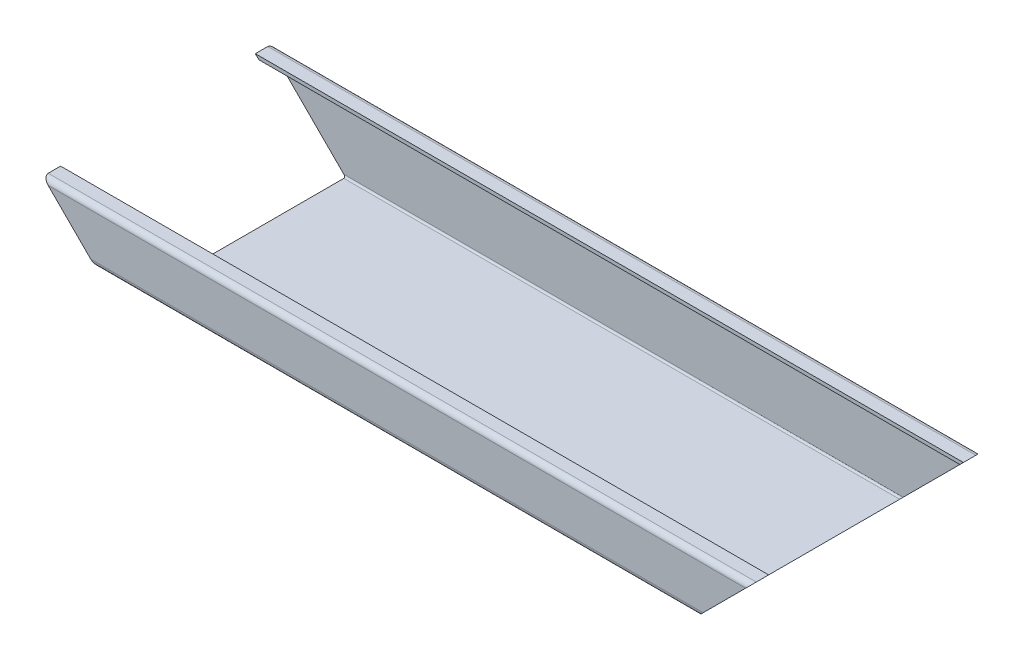
from build123d import *

# Parameters (mm, degrees)
VYSUNOUT_TENKOST_NN_1_DEPTH = 200
ODEBRAT_VYSUNUT_M1_REACH    = 241.596


with BuildPart() as part:
    # Skica1 → Vysunout tenkostěnný1 (new, symmetric)
    with BuildSketch(Plane(origin=(0, 0, 0), x_dir=(0, 0, -1), z_dir=(1, 0, 0))):
        with BuildLine():
            Line((-55, 22.5), (-62, 22.5))
            ThreePointArc((-62, 22.5), (-64.121320344, 21.621320344), (-65, 19.5))
            Line((-65, 19.5), (-65, -4.5))
            ThreePointArc((-65, -4.5), (-64.121320344, -6.621320344), (-62, -7.5))
            Line((-62, -7.5), (-31, -7.5))
            ThreePointArc((-31, -7.5), (-30.292893219, -7.792893219), (-30, -8.5))
            Line((-30, -8.5), (-30, -19.5))
            ThreePointArc((-30, -19.5), (-29.121320344, -21.621320344), (-27, -22.5))
            Line((-27, -22.5), (62, -22.5))
            ThreePointArc((62, -22.5), (64.121320344, -21.621320344), (65, -19.5))
            Line((65, -19.5), (65, 19.5))
            ThreePointArc((65, 19.5), (64.121320344, 21.621320344), (62, 22.5))
            Line((62, 22.5), (55, 22.5))
            Line((55, 22.5), (55, 20.5))
            Line((55, 20.5), (62, 20.5))
            ThreePointArc((62, 20.5), (62.707106781, 20.207106781), (63, 19.5))
            Line((63, 19.5), (63, -19.5))
            ThreePointArc((63, -19.5), (62.707106781, -20.207106781), (62, -20.5))
            Line((62, -20.5), (-27, -20.5))
            ThreePointArc((-27, -20.5), (-27.707106781, -20.207106781), (-28, -19.5))
            Line((-28, -19.5), (-28, -8.5))
            ThreePointArc((-28, -8.5), (-28.878679656, -6.378679656), (-31, -5.5))
            Line((-31, -5.5), (-62, -5.5))
            ThreePointArc((-62, -5.5), (-62.707106781, -5.207106781), (-63, -4.5))
            Line((-63, -4.5), (-63, 19.5))
            ThreePointArc((-63, 19.5), (-62.707106781, 20.207106781), (-62, 20.5))
            Line((-62, 20.5), (-55, 20.5))
            Line((-55, 20.5), (-55, 22.5))
        make_face()
    extrude(amount=VYSUNOUT_TENKOST_NN_1_DEPTH, both=True)

    # Odebrat vysunutím1: up to this face of the body (flat: up to its plane)
    odebrat_vysunut_m1_end = Plane(part.part.faces().sort_by_distance((0, 0, -65))[0])
    # Skica2 → Odebrat vysunutím1 (cut, up to the picked face)
    with BuildSketch(Plane.XY.offset(65), mode=Mode.PRIVATE) as odebrat_vysunut_m1_sk1:
        Polygon((-155, -22.5), (-200, 22.5), (-200, -22.5), align=None)
    odebrat_vysunut_m1_tool1 = split(extrude(odebrat_vysunut_m1_sk1.sketch, amount=-ODEBRAT_VYSUNUT_M1_REACH, mode=Mode.PRIVATE), bisect_by=odebrat_vysunut_m1_end, keep=Keep.BOTH, mode=Mode.PRIVATE)
    # Skica2 → Odebrat vysunutím1 (cut, up to the picked face)
    with BuildSketch(Plane.XY.offset(65), mode=Mode.PRIVATE) as odebrat_vysunut_m1_sk2:
        Polygon((200, 22.5), (200, -22.5), (155, -22.5), align=None)
    odebrat_vysunut_m1_tool2 = split(extrude(odebrat_vysunut_m1_sk2.sketch, amount=-ODEBRAT_VYSUNUT_M1_REACH, mode=Mode.PRIVATE), bisect_by=odebrat_vysunut_m1_end, keep=Keep.BOTH, mode=Mode.PRIVATE)
    add(odebrat_vysunut_m1_tool1.solids().sort_by(Axis((-185, -7.5, 65), (0, 0, -1)))[0], mode=Mode.SUBTRACT)
    add(odebrat_vysunut_m1_tool2.solids().sort_by(Axis((185, -7.5, 65), (0, 0, -1)))[0], mode=Mode.SUBTRACT)


solid = part.part
